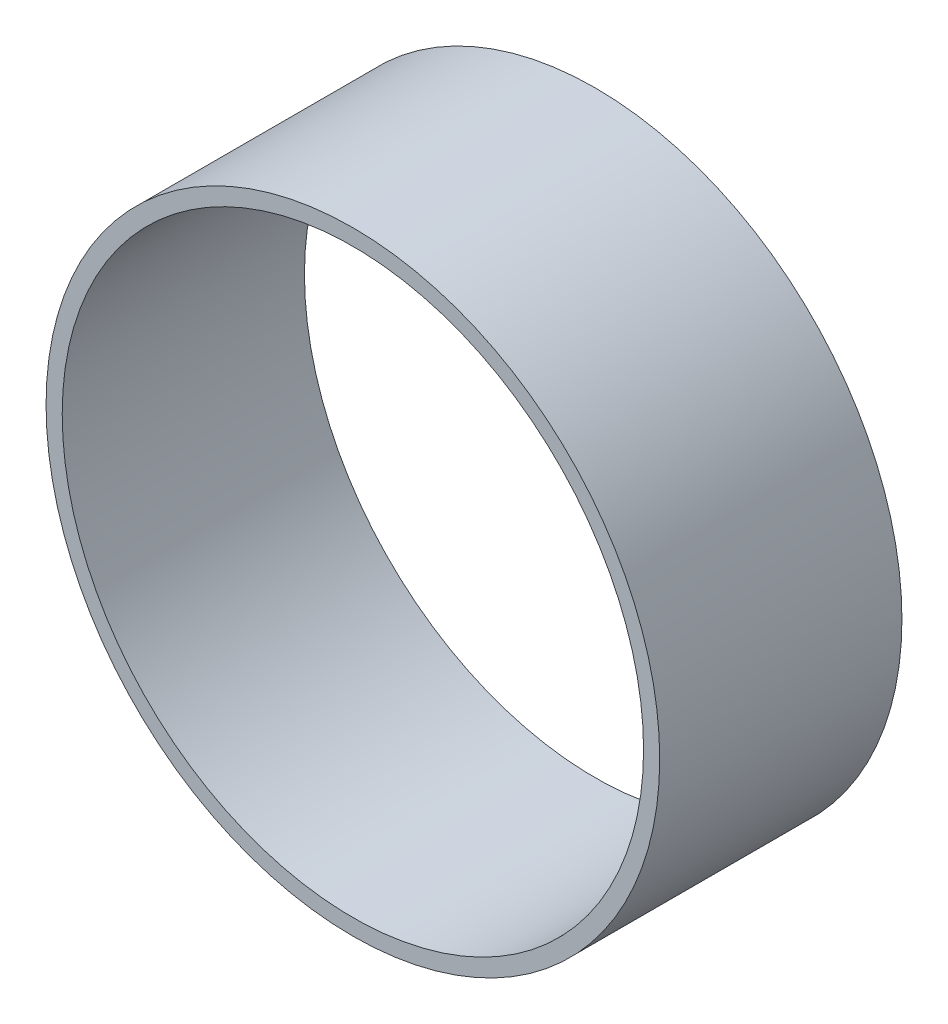
from build123d import *

# Parameters (mm, degrees)
SKETCH1_R           = 190
SKETCH1_R_2         = 180
BOSS_EXTRUDE1_DEPTH = 150


with BuildPart() as part:
    # Sketch1 → Boss-Extrude1 (new body)
    with BuildSketch(Plane.XY):
        Circle(SKETCH1_R)
        Circle(SKETCH1_R_2, mode=Mode.SUBTRACT)
    extrude(amount=BOSS_EXTRUDE1_DEPTH)


solid = part.part
